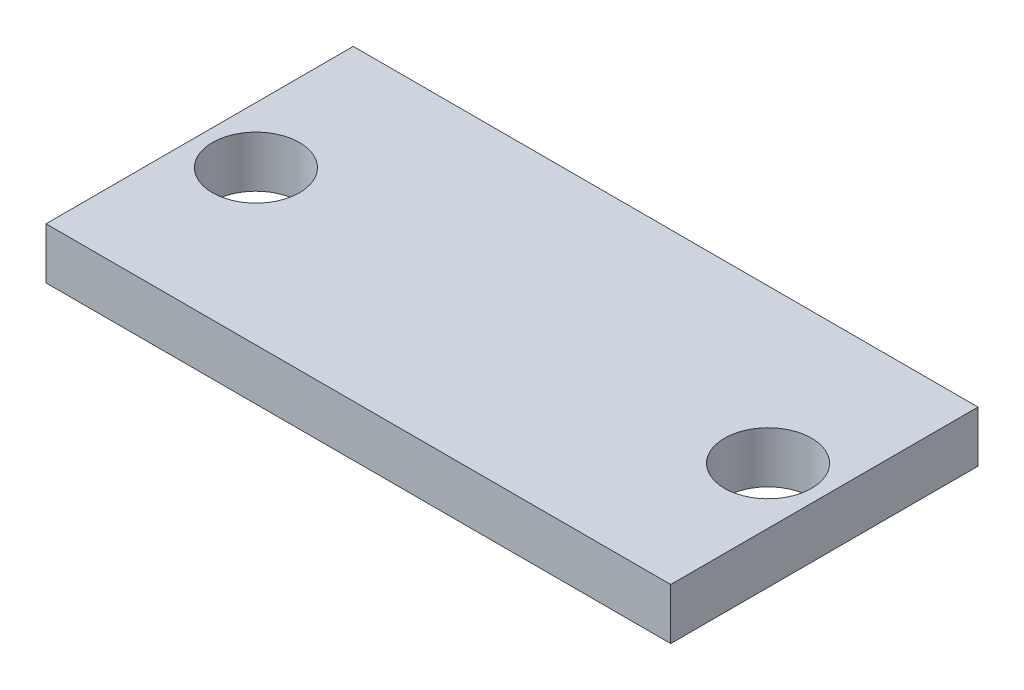
from build123d import *

# Parameters (mm, degrees)
CROQUIS1_R              = 1.7
SALIENTE_EXTRUIR1_DEPTH = 2


with BuildPart() as part:
    # Croquis1 → Saliente-Extruir1 (new body)
    with BuildSketch(Plane(origin=(0, 0, 0), x_dir=(1, 0, 0), z_dir=(0, 1, 0))):
        Polygon((-8.046684223, -2.46171515), (-8.046684223, 2.46171515), (-8.046684223, 6), (8.046684223, 6), (8.046684223, 2.46171515), (8.046684223, -2.46171515), (8.046684223, -6), (-8.046684223, -6), align=None)
        with BuildLine():
            Line((8.046684223, -2.46171515), (8.046684223, 2.46171515))
            ThreePointArc((8.046684223, 2.46171515), (8.827888747, 2.181898598), (9.657649034, 2.173199442))
            ThreePointArc((9.657649034, 2.173199442), (12.2, 0), (9.657649034, -2.173199442))
            ThreePointArc((9.657649034, -2.173199442), (8.827888747, -2.181898598), (8.046684223, -2.46171515))
        make_face()
        with Locations((10, 0)):
            Circle(CROQUIS1_R, mode=Mode.SUBTRACT)
        with BuildLine():
            ThreePointArc((-9.657649034, -2.173199442), (-12.2, 0), (-9.657649034, 2.173199442))
            ThreePointArc((-9.657649034, 2.173199442), (-8.827888747, 2.181898598), (-8.046684223, 2.46171515))
            Line((-8.046684223, 2.46171515), (-8.046684223, -2.46171515))
            ThreePointArc((-8.046684223, -2.46171515), (-8.827888747, -2.181898598), (-9.657649034, -2.173199442))
        make_face()
        with Locations((-10, 0)):
            Circle(CROQUIS1_R, mode=Mode.SUBTRACT)
        with BuildLine():
            Line((-8.046684223, -6), (-8.046684223, -2.46171515))
            ThreePointArc((-8.046684223, -2.46171515), (-8.827888747, -2.181898598), (-9.657649034, -2.173199442))
            ThreePointArc((-9.657649034, -2.173199442), (-11.429480303, -1.672299633), (-12.2, 0))
            Line((-12.2, 0), (-12.2, -6))
            Line((-12.2, -6), (-8.046684223, -6))
        make_face()
        with BuildLine():
            Line((-8.046684223, 2.46171515), (-8.046684223, 6))
            Line((-8.046684223, 6), (-12.2, 6))
            Line((-12.2, 6), (-12.2, 0))
            ThreePointArc((-12.2, 0), (-11.429480303, 1.672299633), (-9.657649034, 2.173199442))
            ThreePointArc((-9.657649034, 2.173199442), (-8.827888747, 2.181898598), (-8.046684223, 2.46171515))
        make_face()
        with BuildLine():
            Line((12.2, 6), (8.046684223, 6))
            Line((8.046684223, 6), (8.046684223, 2.46171515))
            ThreePointArc((8.046684223, 2.46171515), (8.827888747, 2.181898598), (9.657649034, 2.173199442))
            ThreePointArc((9.657649034, 2.173199442), (11.429480303, 1.672299633), (12.2, 0))
            Line((12.2, 0), (12.2, 6))
        make_face()
        with BuildLine():
            ThreePointArc((9.657649034, -2.173199442), (8.827888747, -2.181898598), (8.046684223, -2.46171515))
            Line((8.046684223, -2.46171515), (8.046684223, -6))
            Line((8.046684223, -6), (12.2, -6))
            Line((12.2, -6), (12.2, 0))
            ThreePointArc((12.2, 0), (11.429480303, -1.672299633), (9.657649034, -2.173199442))
        make_face()
    extrude(amount=SALIENTE_EXTRUIR1_DEPTH)


solid = part.part
